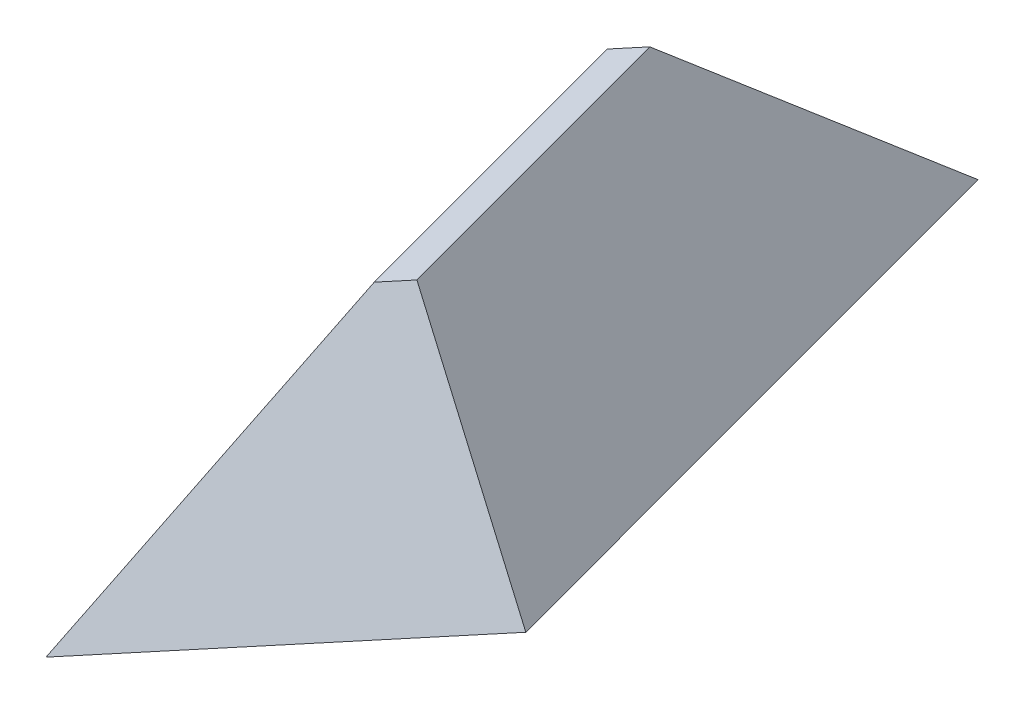
from build123d import *

# Parameters (mm, degrees)
BOSS_EXTRUDE1_DEPTH = 3
BOSS_EXTRUDE1_TAPER = 30


with BuildPart() as part:
    # Sketch1 → Boss-Extrude1 (new body)
    with BuildSketch(Plane(origin=(0, 0, 0), x_dir=(1, 0, 0), z_dir=(0, 1, 0))):
        Polygon((-0.109027256, -9.098030128), (2.870043639, -5.530756897), (0.606547459, 2.901969872), (-2.372523436, -0.66530336), align=None)
    extrude(amount=BOSS_EXTRUDE1_DEPTH, taper=BOSS_EXTRUDE1_TAPER)


solid = part.part
